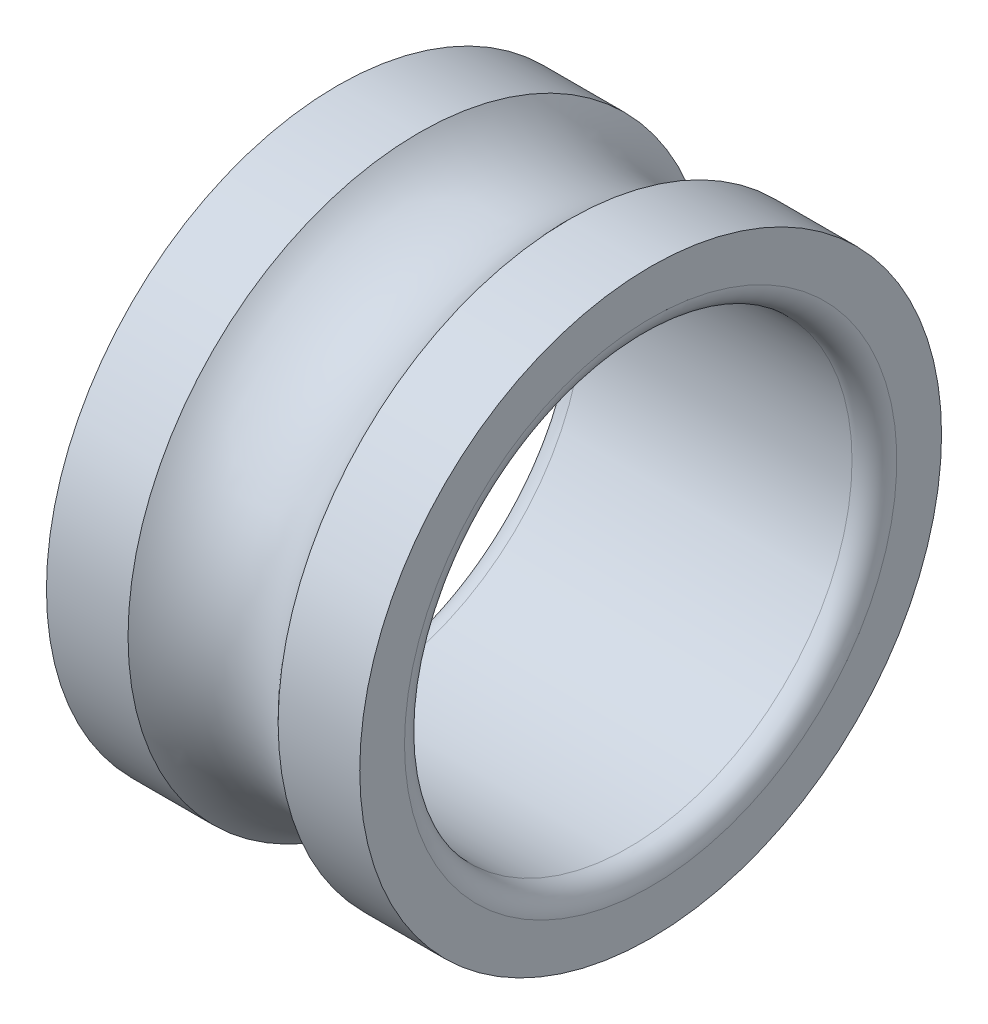
from build123d import *

# Parameters (mm, degrees)
FILLET1_R = 0.5


with BuildPart() as part:
    # Sketch1 → Revolve1 (revolve)
    with BuildSketch(Plane.XY):
        with BuildLine():
            Line((1.677050983, 6.5), (3.5, 6.5))
            Line((3.5, 6.5), (3.5, 5))
            Line((3.5, 5), (-3.5, 5))
            Line((-3.5, 5), (-3.5, 6.5))
            Line((-3.5, 6.5), (-1.677050983, 6.5))
            ThreePointArc((-1.677050983, 6.5), (0, 5.75), (1.677050983, 6.5))
        make_face()
    revolve(axis=Axis((-42.390929705, 0, 0), (1, 0, 0)))

    # Fillet1
    fillet1_edges = [part.edges().sort_by_distance(p)[0] for p in [
        (3.5, -5, 0),
        (-3.5, -5, 0),
    ]]
    fillet(fillet1_edges, radius=FILLET1_R)


solid = part.part
